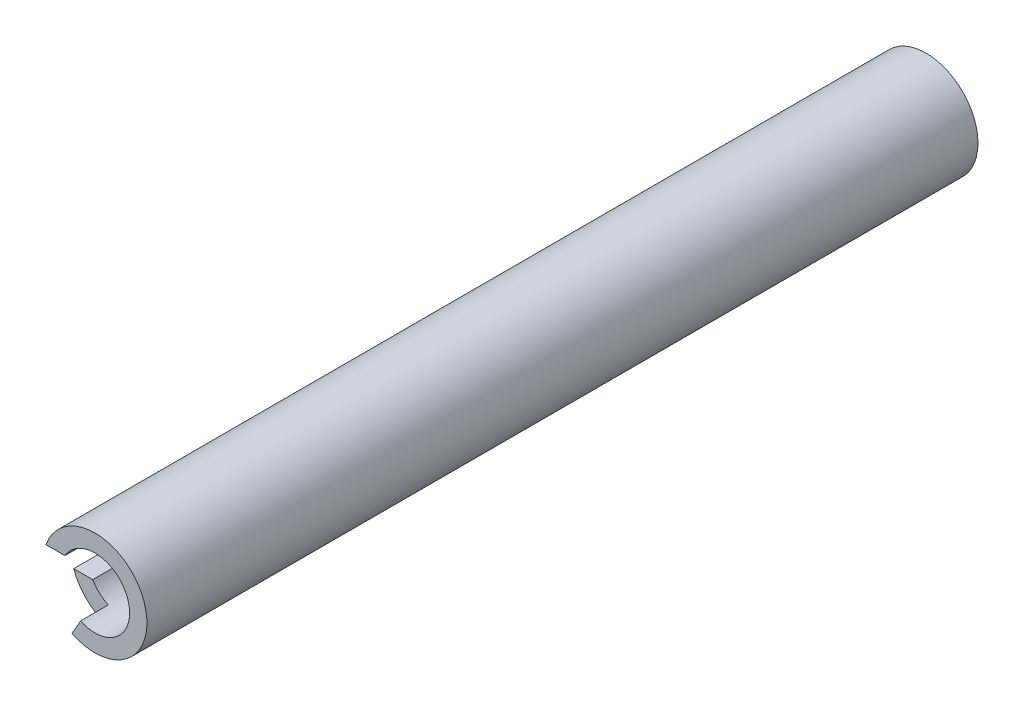
from build123d import *

# Parameters (mm, degrees)
SKETCH1_R           = 19.05
BOSS_EXTRUDE1_DEPTH = 304.8
SKETCH3_R           = 12.7
CUT_EXTRUDE1_DEPTH  = 273.05
SKETCH4_R           = 2.54
CUT_EXTRUDE2_DEPTH  = 31.75
CUT_EXTRUDE3_DEPTH  = 273.05
CUT_EXTRUDE4_DEPTH  = 12.7


with BuildPart() as part:
    # Sketch1 → Boss-Extrude1 (new body)
    with BuildSketch(Plane.XY):
        Circle(SKETCH1_R)
    extrude(amount=BOSS_EXTRUDE1_DEPTH)

    # Sketch3 → Cut-Extrude1 (cut)
    with BuildSketch(Plane.XY.offset(304.8)):
        Circle(SKETCH3_R)
    extrude(amount=-CUT_EXTRUDE1_DEPTH, mode=Mode.SUBTRACT)

    # Sketch4 → Cut-Extrude2 (cut)
    with BuildSketch(Plane(origin=(0, 0, 0), x_dir=(-1, 0, 0), z_dir=(0, 0, -1))):
        Circle(SKETCH4_R)
    extrude(amount=-CUT_EXTRUDE2_DEPTH, mode=Mode.SUBTRACT)

    # Sketch5 → Cut-Extrude3 (cut)
    with BuildSketch(Plane.XY.offset(307.34)):
        Polygon((-12.7, 6.35), (-8.710116392, 6.35), (-8.710116392, -6.35), (-20.268037983, -6.35), (-20.268037983, 6.35), align=None)
    extrude(amount=-CUT_EXTRUDE3_DEPTH, mode=Mode.SUBTRACT)

    # Sketch7 → Cut-Extrude4 (cut)
    with BuildSketch(Plane.XY.offset(307.34)):
        Polygon((-17.960512242, -6.35), (-18.177595791, -12.696288264), (-18.177595791, -17.489691447), (-8.665474889, -17.489691447), (-4.23331347, -9.662232457), (-8.307734332, -6.35), align=None)
    extrude(amount=-CUT_EXTRUDE4_DEPTH, mode=Mode.SUBTRACT)


solid = part.part
